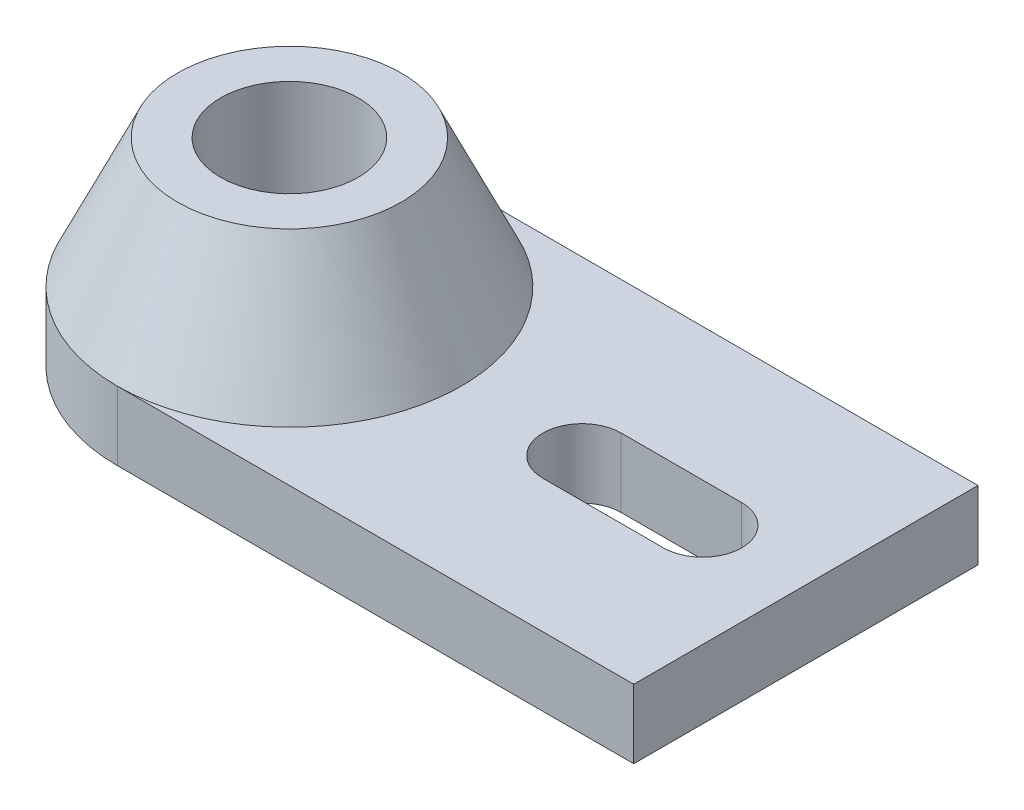
from build123d import *

# Parameters (mm, degrees)
SKETCH2_R           = 13
SKETCH1_R           = 20
BOSS_EXTRUDE1_DEPTH = 8
CUT_EXTRUDE2_DEPTH  = 8
SKETCH7_R           = 8
CUT_EXTRUDE3_DEPTH  = 24


with BuildPart() as part:
    # Sketch2 → Loft1 section 0
    with BuildSketch(Plane(origin=(0, 15, 0), x_dir=(1, 0, 0), z_dir=(0, 1, 0))):
        Circle(SKETCH2_R)
    # Sketch1 → Loft1 section 1
    with BuildSketch(Plane(origin=(0, 0, 0), x_dir=(1, 0, 0), z_dir=(0, 1, 0))):
        Circle(SKETCH1_R)
    loft()


with BuildPart() as body_2:
    # Sketch5 → Boss-Extrude1 (new body)
    with BuildSketch(Plane(origin=(0, 0, 0), x_dir=(1, 0, 0), z_dir=(0, 1, 0))):
        with BuildLine():
            Line((0, 20), (60, 20))
            Line((60, 20), (60, -20))
            Line((60, -20), (0, -20))
            ThreePointArc((0, -20), (-20, 0), (0, 20))
        make_face()
    extrude(amount=-BOSS_EXTRUDE1_DEPTH)

    # Sketch6 → Cut-Extrude2 (cut)
    with BuildSketch(Plane(origin=(0, 0, 0), x_dir=(1, 0, 0), z_dir=(0, 1, 0))):
        with BuildLine():
            Line((34, 4.551048267), (48, 4.551048267))
            ThreePointArc((48, 4.551048267), (52.551048267, 0), (48, -4.551048267))
            Line((48, -4.551048267), (34, -4.551048267))
            ThreePointArc((34, -4.551048267), (29.448951733, 0), (34, 4.551048267))
        make_face()
    extrude(amount=-CUT_EXTRUDE2_DEPTH, mode=Mode.SUBTRACT)


with BuildPart() as cut_extrude3_tool:
    # Sketch7 → Cut-Extrude3 (new body, through all)
    with BuildSketch(Plane(origin=(0, 15, 0), x_dir=(1, 0, 0), z_dir=(0, 1, 0))):
        Circle(SKETCH7_R)
    extrude(amount=-CUT_EXTRUDE3_DEPTH)


with BuildPart() as part_1:
    add(part.part)

    # Cut-Extrude3: cut by cut_extrude3_tool
    add(cut_extrude3_tool.part, mode=Mode.SUBTRACT)


with BuildPart() as body_2_1:
    add(body_2.part)

    # Cut-Extrude3: cut by cut_extrude3_tool
    add(cut_extrude3_tool.part, mode=Mode.SUBTRACT)


solid = Compound([part_1.part, body_2_1.part])
